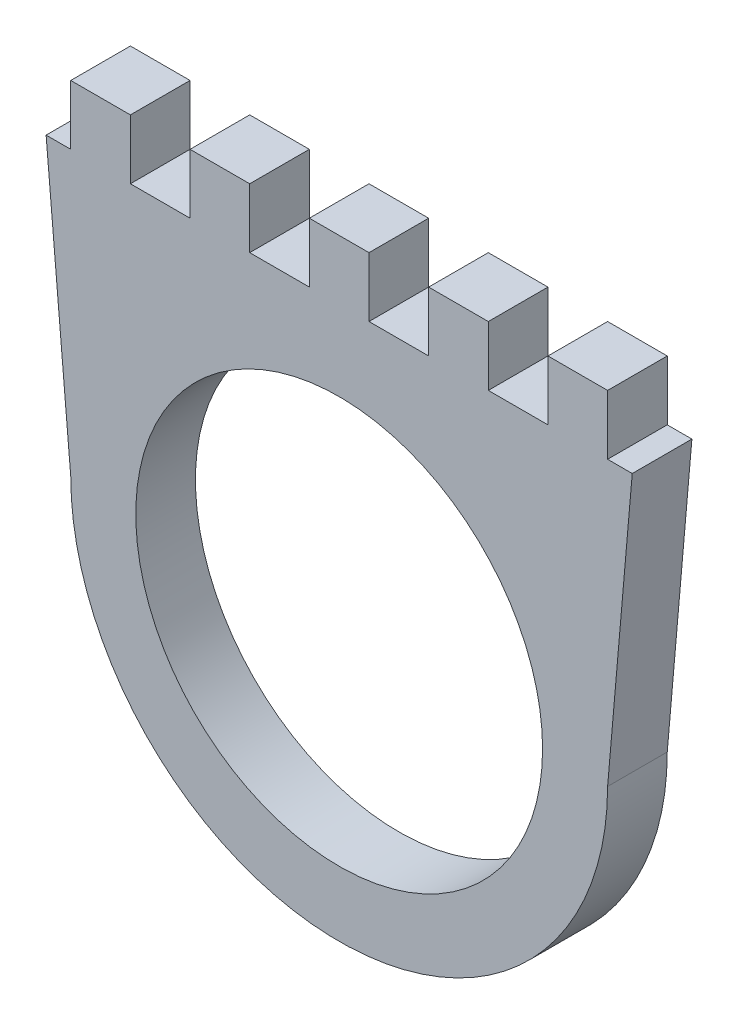
from build123d import *

# Parameters (mm, degrees)
BOSS_EXTRU_12_DEPTH        = 5
ESQUISSE4_R                = 17.05
ENL_V_MAT_EXTRU_1_DEPTH    = 5
ESQUISSE5_W                = 5
ESQUISSE5_H                = 5
ENL_V_MAT_EXTRU_2_DEPTH    = 10
R_P_TITION_LIN_AIRE1_COUNT = 4
R_P_TITION_LIN_AIRE1_PITCH = 10
ESQUISSE6_W                = 13.329947017
ESQUISSE6_H                = 14.257676648
ESQUISSE6_W_2              = 10.080555657
ESQUISSE6_H_2              = 33.311834117
ENL_V_MAT_EXTRU_3_DEPTH    = 10


with BuildPart() as part:
    # Esquisse3 → Boss.-Extru.12 (new body)
    with BuildSketch(Plane.XY):
        with BuildLine():
            Line((-22.5, 0), (-25, 28.75))
            Line((-25, 28.75), (25, 28.75))
            Line((25, 28.75), (22.5, 0))
            ThreePointArc((22.5, 0), (0, -22.5), (-22.5, 0))
        make_face()
    extrude(amount=BOSS_EXTRU_12_DEPTH)

    # Esquisse4 → Enlèv. mat.-Extru.1 (cut)
    with BuildSketch(Plane.XY.offset(5)):
        Circle(ESQUISSE4_R)
    extrude(amount=-ENL_V_MAT_EXTRU_1_DEPTH, mode=Mode.SUBTRACT)

    # Esquisse5 → Enlèv. mat.-Extru.2 (cut)
    with BuildSketch(Plane.XY.offset(5)):
        with Locations((-15, 26.25)):
            Rectangle(ESQUISSE5_W, ESQUISSE5_H)
    enl_v_mat_extru_2 = extrude(amount=-ENL_V_MAT_EXTRU_2_DEPTH, mode=Mode.SUBTRACT)

    # Répétition linéaire1: Enlèv. mat.-Extru.2 ×4
    with Locations(*[(i * R_P_TITION_LIN_AIRE1_PITCH, 0, 0) for i in range(1, R_P_TITION_LIN_AIRE1_COUNT)]):
        add(enl_v_mat_extru_2, mode=Mode.SUBTRACT)

    # Esquisse6 → Enlèv. mat.-Extru.3 (cut)
    with BuildSketch(Plane.XY.offset(5)):
        with Locations((29.164973509, 30.878838324)):
            Rectangle(ESQUISSE6_W, ESQUISSE6_H)
        with Locations((-27.540277829, 40.405917059)):
            Rectangle(ESQUISSE6_W_2, ESQUISSE6_H_2)
    extrude(amount=-ENL_V_MAT_EXTRU_3_DEPTH, mode=Mode.SUBTRACT)


solid = part.part
